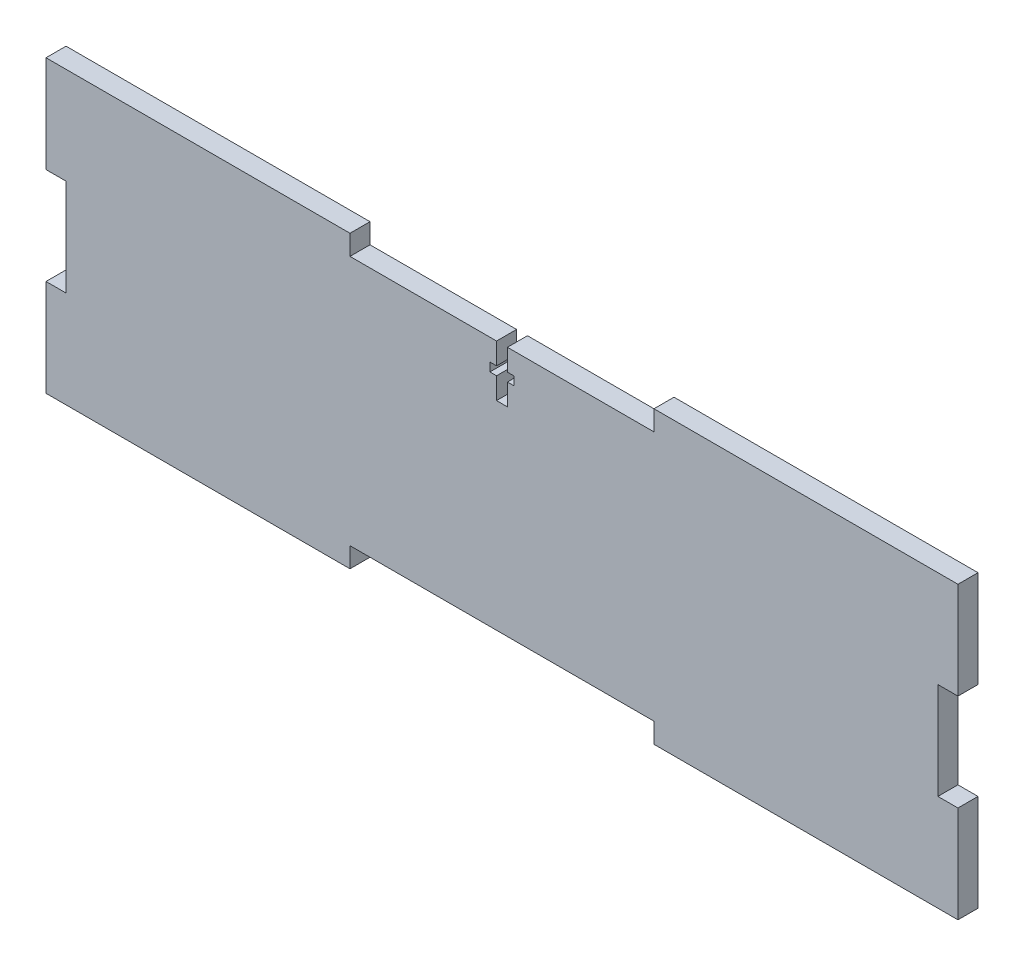
from build123d import *

# Parameters (mm, degrees)
SKETCH1_W           = 231.14
SKETCH1_H           = 73.66
BOSS_EXTRUDE1_DEPTH = 5.08
SKETCH2_W           = 77.046666666
SKETCH2_H           = 5.08
CUT_EXTRUDE1_DEPTH  = 6.08
SKETCH3_W           = 5.08
SKETCH3_H           = 24.553333334
CUT_EXTRUDE2_DEPTH  = 6.08
SKETCH5_W           = 2.7559
SKETCH5_H           = 13.081
CUT_EXTRUDE4_DEPTH  = 6.08
SKETCH6_W           = 6.096
SKETCH6_H           = 2.1717
CUT_EXTRUDE5_DEPTH  = 6.08


with BuildPart() as part:
    # Sketch1 → Boss-Extrude1 (new body)
    with BuildSketch(Plane.XY):
        Rectangle(SKETCH1_W, SKETCH1_H)
    extrude(amount=BOSS_EXTRUDE1_DEPTH)

    # Sketch2 → Cut-Extrude1 (cut, through all)
    with BuildSketch(Plane.XY.offset(5.08)):
        with Locations((0, -34.29)):
            Rectangle(SKETCH2_W, SKETCH2_H)
        with Locations((0, 34.29)):
            Rectangle(SKETCH2_W, SKETCH2_H)
    extrude(amount=-CUT_EXTRUDE1_DEPTH, mode=Mode.SUBTRACT)

    # Sketch3 → Cut-Extrude2 (cut, through all)
    with BuildSketch(Plane.XY.offset(5.08)):
        with Locations((-113.03, 0)):
            Rectangle(SKETCH3_W, SKETCH3_H)
        with Locations((113.03, 0)):
            Rectangle(SKETCH3_W, SKETCH3_H)
    extrude(amount=-CUT_EXTRUDE2_DEPTH, mode=Mode.SUBTRACT)

    # Sketch5 → Cut-Extrude4 (cut, through all)
    with BuildSketch(Plane.XY.offset(5.08)):
        with Locations((0, 25.2095)):
            Rectangle(SKETCH5_W, SKETCH5_H)
    extrude(amount=-CUT_EXTRUDE4_DEPTH, mode=Mode.SUBTRACT)

    # Sketch6 → Cut-Extrude5 (cut, through all)
    with BuildSketch(Plane.XY.offset(5.08)):
        with Locations((0, 25.2095)):
            Rectangle(SKETCH6_W, SKETCH6_H)
    extrude(amount=-CUT_EXTRUDE5_DEPTH, mode=Mode.SUBTRACT)


solid = part.part
